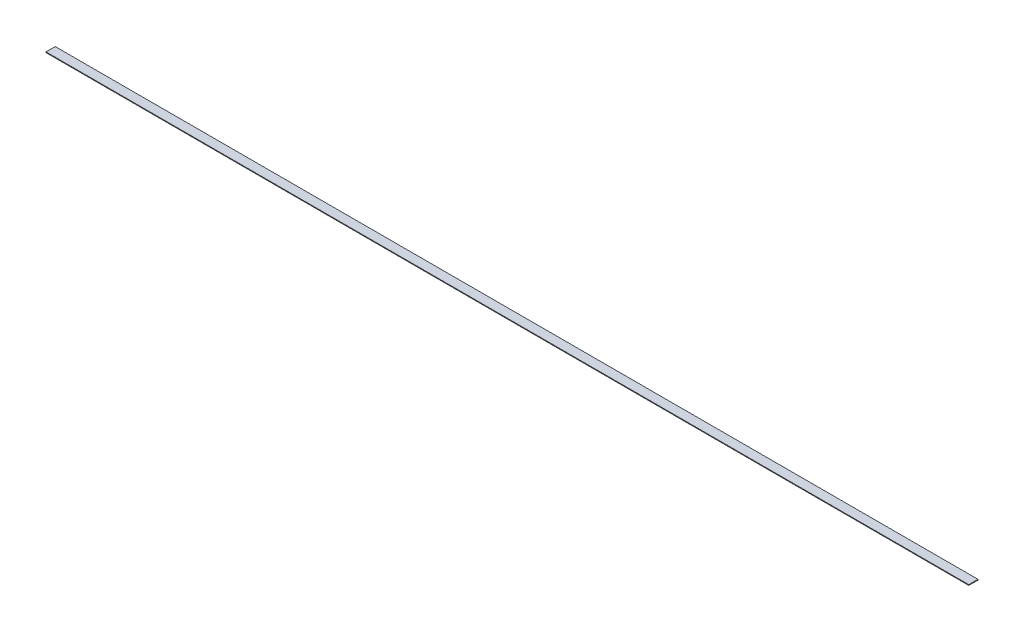
from build123d import *

# Parameters (mm, degrees)
SKETCH_1_W      = 20
SKETCH_1_H      = 1.5
EXTRUDE_1_DEPTH = 2000


with BuildPart() as part:
    # Эскиз1 → Бобышка-Вытянуть1 (new body)
    with BuildSketch(Plane(origin=(0, 0, 0), x_dir=(0, 0, -1), z_dir=(1, 0, 0))):
        Rectangle(SKETCH_1_W, SKETCH_1_H)
    extrude(amount=EXTRUDE_1_DEPTH)


solid = part.part
